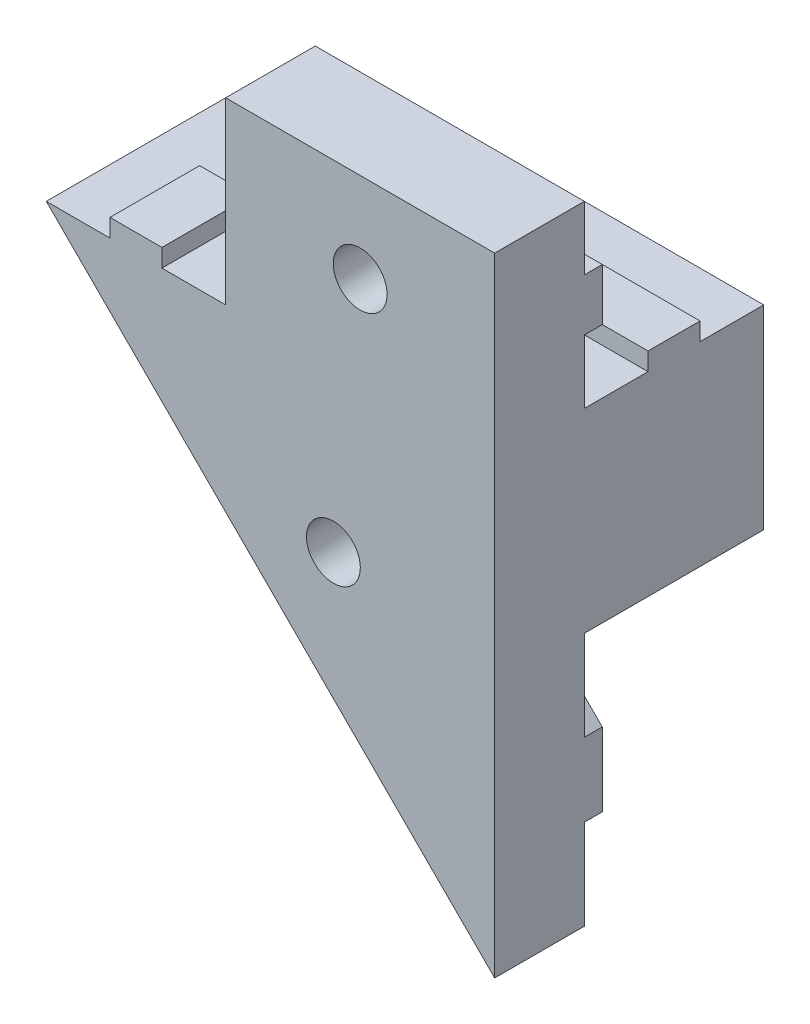
from build123d import *

# Parameters (mm, degrees)
MAIN_DEPTH          = 15
SKETCH4_W           = 15
SKETCH4_H           = 10
CUT_EXTRUDE2_DEPTH  = 10
SKETCH2_W           = 15
SKETCH2_H           = 2.9
BOSS_EXTRUDE3_DEPTH = 1
SKETCH5_W           = 2.9
SKETCH5_H           = 12.715728752
BOSS_EXTRUDE4_DEPTH = 1
SKETCH6_R           = 1.5
BOSS_EXTRUDE5_DEPTH = 5
BOSS_EXTRUDE6_DEPTH = 1
SKETCH8_W           = 2.9
SKETCH8_H           = 10
BOSS_EXTRUDE7_DEPTH = 1
SKETCH9_W           = 1
SKETCH9_H           = 2.9
BOSS_EXTRUDE8_DEPTH = 10
SKETCH11_R          = 1.25
CUT_EXTRUDE4_DEPTH  = 26
SKETCH12_R          = 1.5
CUT_EXTRUDE5_DEPTH  = 16
SKETCH13_W          = 15
SKETCH13_H          = 2.9
BOSS_EXTRUDE9_DEPTH = 1
SKETCH15_W          = 10
SKETCH15_H          = 10
CUT_EXTRUDE7_DEPTH  = 11
SKETCH16_R          = 1.5
CUT_EXTRUDE8_DEPTH  = 16
SKETCH14_W          = 30.791050847
SKETCH14_H          = 42.890305085
CUT_EXTRUDE6_DEPTH  = 26


with BuildPart() as part:
    # Sketch1 → Main (new body)
    with BuildSketch(Plane.XY):
        Polygon((0, 0), (-10, 0), (-10, 10), (-25, 10), (-25, -10.857864376), (-16.008621971, -1.866486348), (-8.937554159, -8.937554159), align=None)
    extrude(amount=MAIN_DEPTH)

    # Sketch4 → Cut-Extrude2 (cut)
    with BuildSketch(Plane(origin=(0, 0, 0), x_dir=(-1, 0, 0), z_dir=(0, 0, -1))):
        with Locations((17.5, 5)):
            Rectangle(SKETCH4_W, SKETCH4_H)
    extrude(amount=-CUT_EXTRUDE2_DEPTH, mode=Mode.SUBTRACT)

    # Sketch2 → Boss-Extrude3 (add)
    with BuildSketch(Plane(origin=(0, 0, 10), x_dir=(-1, 0, 0), z_dir=(0, 0, -1))):
        with Locations((17.5, 5)):
            Rectangle(SKETCH2_W, SKETCH2_H)
    extrude(amount=BOSS_EXTRUDE3_DEPTH)

    # Sketch5 → Boss-Extrude4 (add)
    with BuildSketch(Plane(origin=(-7.071067812, 7.071067812, 0), x_dir=(0, 0, -1), z_dir=(0.707106781, -0.707106781, 0))):
        with Locations((-5, -18.997474683)):
            Rectangle(SKETCH5_W, SKETCH5_H)
    extrude(amount=BOSS_EXTRUDE4_DEPTH)

    # Sketch6 → Boss-Extrude5 (add)
    with BuildSketch(Plane.XY.offset(10)):
        Polygon((-25, -10.857864376), (-16.008621971, -1.866486348), (-8.937554159, -8.937554159), (-25, -25), align=None)
        with Locations((-16.008621971, -8.937554159)):
            Circle(SKETCH6_R, mode=Mode.SUBTRACT)
    extrude(amount=BOSS_EXTRUDE5_DEPTH)

    # Sketch7 → Boss-Extrude6 (add)
    with BuildSketch(Plane(origin=(0, 0, 10), x_dir=(-1, 0, 0), z_dir=(0, 0, -1))):
        Polygon((13.498392898, -4.376715421), (25, -15.878322523), (25, -19.979541854), (11.447783233, -6.427325086), align=None)
    extrude(amount=BOSS_EXTRUDE6_DEPTH)

    # Sketch8 → Boss-Extrude7 (add)
    with BuildSketch(Plane(origin=(0, 0, 0), x_dir=(1, 0, 0), z_dir=(0, 1, 0))):
        with Locations((-5, -10)):
            Rectangle(SKETCH8_W, SKETCH8_H)
    extrude(amount=BOSS_EXTRUDE7_DEPTH)

    # Sketch11 → Cut-Extrude4 (cut, through all)
    with BuildSketch(Plane(origin=(0, 0, 0), x_dir=(1, 0, 0), z_dir=(0, 1, 0))):
        with Locations((-5, -5)):
            Circle(SKETCH11_R)
    extrude(amount=-CUT_EXTRUDE4_DEPTH, mode=Mode.SUBTRACT)

    # Sketch12 → Cut-Extrude5 (cut, through all)
    with BuildSketch(Plane.XY.offset(15)):
        with Locations((-16.008621971, -8.937554159)):
            Circle(SKETCH12_R)
    extrude(amount=-CUT_EXTRUDE5_DEPTH, mode=Mode.SUBTRACT)

    # Sketch13 → Boss-Extrude9 (add)
    with BuildSketch(Plane(origin=(0, 0, 0), x_dir=(1, 0, 0), z_dir=(0, 1, 0))):
        with Locations((-17.5, -5)):
            Rectangle(SKETCH13_W, SKETCH13_H)
    extrude(amount=BOSS_EXTRUDE9_DEPTH)


with BuildPart() as body_2:
    # Sketch9 → Boss-Extrude8 (new body)
    with BuildSketch(Plane.XY.offset(15)):
        with Locations((-9.5, 5)):
            Rectangle(SKETCH9_W, SKETCH9_H)
    extrude(amount=-BOSS_EXTRUDE8_DEPTH)


with BuildPart() as cut_extrude7_tool:
    # Sketch15 → Cut-Extrude7 (new body, through all)
    with BuildSketch(Plane(origin=(0, 0, 10), x_dir=(-1, 0, 0), z_dir=(0, 0, -1))):
        with Locations((5, 5)):
            Rectangle(SKETCH15_W, SKETCH15_H)
    extrude(amount=CUT_EXTRUDE7_DEPTH)


with BuildPart() as part_1:
    add(part.part)

    # Cut-Extrude7: cut by cut_extrude7_tool
    add(cut_extrude7_tool.part, mode=Mode.SUBTRACT)

    # Sketch16 → Cut-Extrude8 (cut, through all)
    with BuildSketch(Plane.XY.offset(15)):
        with Locations((-17.5, 5)):
            Circle(SKETCH16_R)
    extrude(amount=-CUT_EXTRUDE8_DEPTH, mode=Mode.SUBTRACT)


with BuildPart() as body_2_1:
    add(body_2.part)

    # Cut-Extrude7: cut by cut_extrude7_tool
    add(cut_extrude7_tool.part, mode=Mode.SUBTRACT)


with BuildPart() as body_3:
    # Mirror1: mirrored copy
    add(part_1.part.mirror(Plane.ZY.offset(30)))


with BuildPart() as cut_extrude6_tool:
    # Sketch14 → Cut-Extrude6 (new body, through all)
    with BuildSketch(Plane(origin=(-25, 0, -10), x_dir=(0, 0, -1), z_dir=(1, 0, 0))):
        with Locations((-11.471050848, -6.763186441)):
            Rectangle(SKETCH14_W, SKETCH14_H)
    extrude(amount=CUT_EXTRUDE6_DEPTH)


with BuildPart() as part_2:
    add(part_1.part)

    # Cut-Extrude6: cut by cut_extrude6_tool
    add(cut_extrude6_tool.part, mode=Mode.SUBTRACT)


with BuildPart() as body_2_2:
    add(body_2_1.part)

    # Cut-Extrude6: cut by cut_extrude6_tool
    add(cut_extrude6_tool.part, mode=Mode.SUBTRACT)


solid = body_3.part
